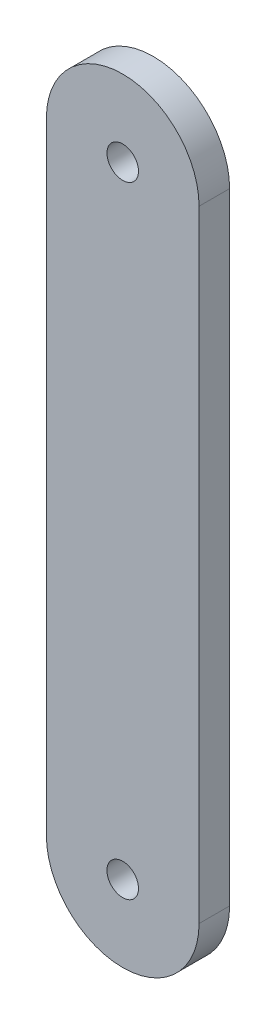
from build123d import *

# Parameters (mm, degrees)
CROQUIS1_R              = 1.55
SALIENTE_EXTRUIR1_DEPTH = 3


with BuildPart() as part:
    # Croquis1 → Saliente-Extruir1 (new body)
    with BuildSketch(Plane.XY):
        with BuildLine():
            Line((-7.5, 0), (-7.5, 61.03))
            ThreePointArc((-7.5, 61.03), (0, 68.53), (7.5, 61.03))
            Line((7.5, 61.03), (7.5, 0))
            ThreePointArc((7.5, 0), (0, -7.5), (-7.5, 0))
        make_face()
        Circle(CROQUIS1_R, mode=Mode.SUBTRACT)
        with Locations((0, 61.03)):
            Circle(CROQUIS1_R, mode=Mode.SUBTRACT)
    extrude(amount=SALIENTE_EXTRUIR1_DEPTH)


solid = part.part
